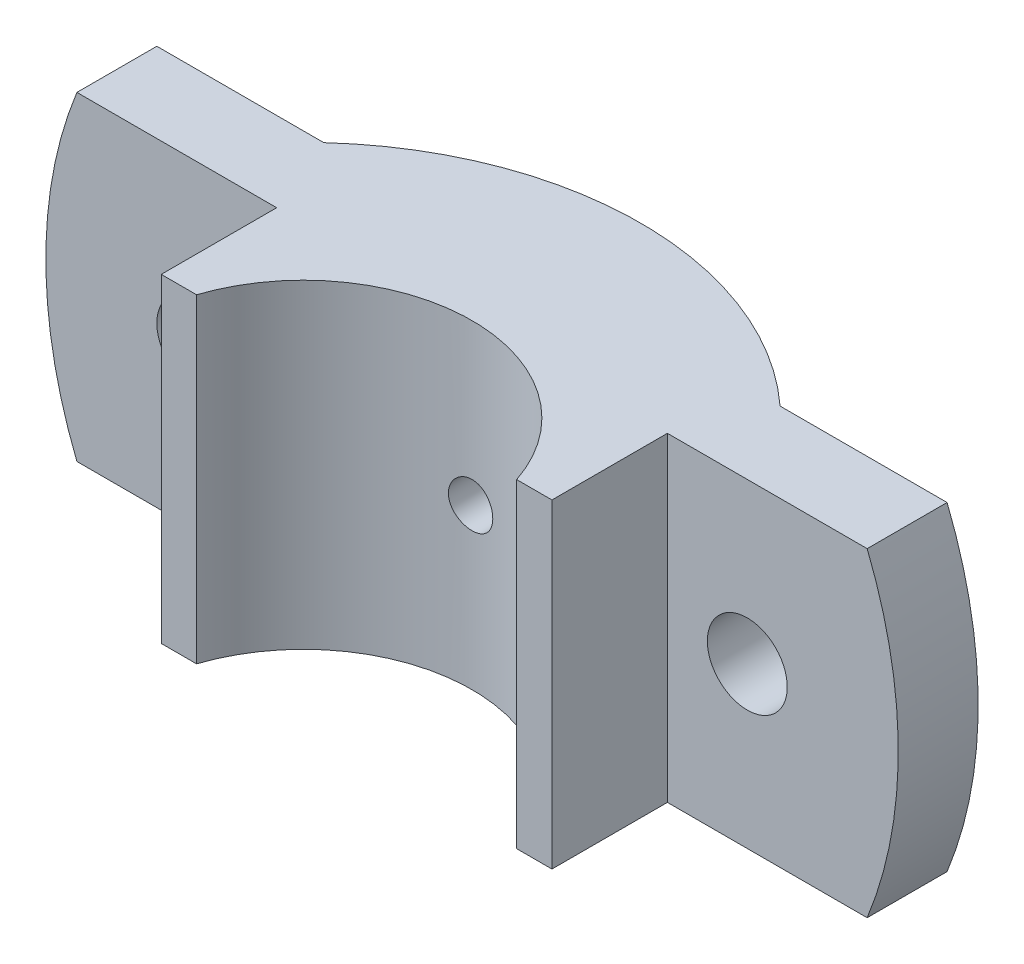
from build123d import *

# Parameters (mm, degrees)
BOSS_EXTRUDE1_DEPTH = 18
SKETCH3_R           = 4.5
CUT_EXTRUDE1_DEPTH  = 58.515215378
CUT_EXTRUDE5_DEPTH  = 58.515215378
CUT_EXTRUDE10_REACH = 57.785


with BuildPart() as part:
    # Sketch2 → Boss-Extrude1 (new, symmetric)
    with BuildSketch(Plane(origin=(0, 0, 0), x_dir=(1, 0, 0), z_dir=(0, 1, 0))):
        with BuildLine():
            Line((18.027756377, 6), (22, 6))
            Line((22, 6), (22, 19))
            Line((22, 19), (50, 19))
            Line((50, 19), (50, 28))
            Line((50, 28), (25.690465157, 28))
            ThreePointArc((25.690465157, 28), (0, 38), (-25.690465157, 28))
            Line((-25.690465157, 28), (-50, 28))
            Line((-50, 28), (-50, 19))
            Line((-50, 19), (-22, 19))
            Line((-22, 19), (-22, 6))
            Line((-22, 6), (-18.027756377, 6))
            ThreePointArc((-18.027756377, 6), (0, 19), (18.027756377, 6))
        make_face()
    extrude(amount=BOSS_EXTRUDE1_DEPTH, both=True)

    # Sketch3 → Cut-Extrude1 (cut, through all)
    with BuildSketch(Plane(origin=(0, 0, -28), x_dir=(-1, 0, 0), z_dir=(0, 0, -1))):
        with Locations((-31, 0)):
            Circle(SKETCH3_R)
    cut_extrude1 = extrude(amount=-CUT_EXTRUDE1_DEPTH, mode=Mode.SUBTRACT)

    # Mirror1: Cut-Extrude1 across plane
    add(cut_extrude1.mirror(Plane(origin=(0, 0, 0), x_dir=(0, 0, 1), z_dir=(1, 0, 0))), mode=Mode.SUBTRACT)

    # Sketch4 → Cut-Extrude5 (cut, through all)
    with BuildSketch(Plane(origin=(0, 0, -28), x_dir=(-1, 0, 0), z_dir=(0, 0, -1))):
        with BuildLine():
            ThreePointArc((44.497190923, -18), (48, 0), (44.497190923, 18))
            Line((44.497190923, 18), (50, 18))
            Line((50, 18), (50, -18))
            Line((50, -18), (44.497190923, -18))
        make_face()
        with BuildLine():
            ThreePointArc((-44.497190923, 18), (-48, 0), (-44.497190923, -18))
            Line((-44.497190923, -18), (-50, -18))
            Line((-50, -18), (-50, 18))
            Line((-50, 18), (-44.497190923, 18))
        make_face()
    extrude(amount=-CUT_EXTRUDE5_DEPTH, mode=Mode.SUBTRACT)

    # Sketch10 → CBORE for M5 Hex Head Bolt5 (revolve, cut)
    with BuildSketch(Plane(origin=(0, 0, -38), x_dir=(0, 1, 0), z_dir=(1, 0, 0))):
        Polygon((0, 0), (0, 32), (2.5, 32), (2.5, 13.300129879), (2.9995, 13), (3, 0), align=None)
    revolve(axis=Axis((0, 0, -44.35), (0, 0, 1)), mode=Mode.SUBTRACT)

    # Sketch11 → Cut-Extrude10 (cut, up to next)
    with BuildSketch(Plane(origin=(0, 0, -28), x_dir=(-1, 0, 0), z_dir=(0, 0, -1)), mode=Mode.PRIVATE) as cut_extrude10_sk1:
        with BuildLine():
            Line((25.690465157, 6.637683312), (25.690465157, -6.637683312))
            ThreePointArc((25.690465157, -6.637683312), (22.5, 0), (25.690465157, 6.637683312))
        make_face()
    cut_extrude10_tool1 = extrude(cut_extrude10_sk1.sketch, amount=CUT_EXTRUDE10_REACH, mode=Mode.PRIVATE) & part.part
    cut_extrude10 = cut_extrude10_tool1.solids().sort_by_distance((-24.391227, 0, -28))[0]
    add(cut_extrude10, mode=Mode.SUBTRACT)

    # Mirror2: Cut-Extrude10 across plane
    add(cut_extrude10.mirror(Plane(origin=(0, 0, 0), x_dir=(0, 0, 1), z_dir=(1, 0, 0))), mode=Mode.SUBTRACT)


solid = part.part
